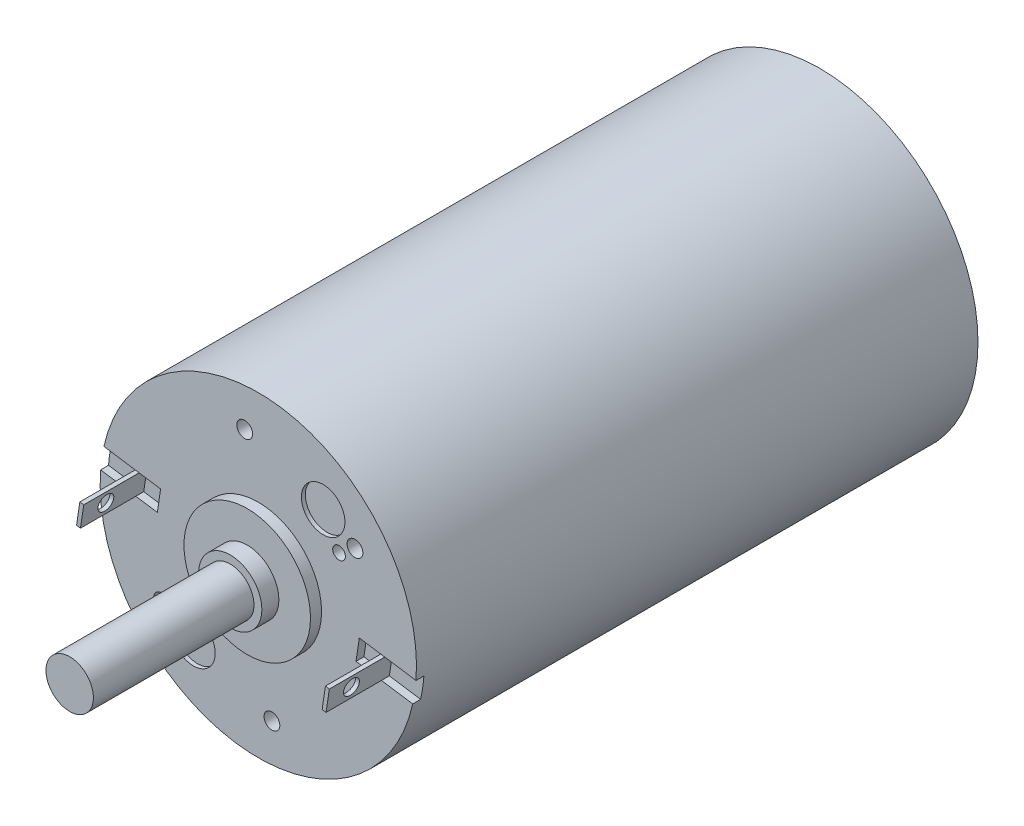
from build123d import *

# Parameters (mm, degrees)
SKETCH1_R           = 20
BOSS_EXTRUDE1_DEPTH = 71
SKETCH2_R           = 8
BOSS_EXTRUDE2_DEPTH = 1.4
SKETCH3_R           = 4
BOSS_EXTRUDE3_DEPTH = 2.15
SKETCH4_R           = 3
BOSS_EXTRUDE4_DEPTH = 20.3
SKETCH5_R           = 1
SKETCH5_R_2         = 0.8
CUT_EXTRUDE1_DEPTH  = 3
CUT_EXTRUDE2_DEPTH  = 1
BOSS_EXTRUDE5_DEPTH = 8
SKETCH8_R           = 2.75
CUT_EXTRUDE3_DEPTH  = 0.5
CUT_EXTRUDE4_REACH  = 105.809
SKETCH9_R           = 1
CUT_EXTRUDE5_REACH  = 137.209
CUT_EXTRUDE5_START  = -31.4
SKETCH9_2_R         = 1
SKETCH10_R          = 1.5
SKETCH10_R_2        = 1.75
CUT_EXTRUDE6_DEPTH  = 5


with BuildPart() as part:
    # Sketch1 → Boss-Extrude1 (new body)
    with BuildSketch(Plane.XY):
        Circle(SKETCH1_R)
    extrude(amount=BOSS_EXTRUDE1_DEPTH)

    # Sketch2 → Boss-Extrude2 (add)
    with BuildSketch(Plane.XY.offset(71)):
        Circle(SKETCH2_R)
    extrude(amount=BOSS_EXTRUDE2_DEPTH)

    # Sketch3 → Boss-Extrude3 (add)
    with BuildSketch(Plane.XY.offset(72.4)):
        Circle(SKETCH3_R)
    extrude(amount=BOSS_EXTRUDE3_DEPTH)

    # Sketch4 → Boss-Extrude4 (add)
    with BuildSketch(Plane.XY.offset(74.55)):
        Circle(SKETCH4_R)
    extrude(amount=BOSS_EXTRUDE4_DEPTH)

    # Sketch5 → Cut-Extrude1 (cut)
    with BuildSketch(Plane.XY.offset(71)):
        with Locations((12.218624281, 9.041306359)):
            Circle(SKETCH5_R)
        with Locations((-12.218624281, -9.041306359)):
            Circle(SKETCH5_R)
        with Locations((-1.720688849, 15.102292206)):
            Circle(SKETCH5_R)
        with Locations((1.720688849, -15.102292206)):
            Circle(SKETCH5_R)
        with Locations((10.20898213, 7.554249392)):
            Circle(SKETCH5_R_2)
        with Locations((-10.20898213, -7.554249392)):
            Circle(SKETCH5_R_2)
    extrude(amount=-CUT_EXTRUDE1_DEPTH, mode=Mode.SUBTRACT)

    # Sketch6 → Cut-Extrude2 (cut)
    with BuildSketch(Plane.XY.offset(71)):
        Polygon((-19.987250443, 1.571566014), (-12.76743464, 0.492557313), (-12.353568289, 3.26180173), (-19.573384092, 4.340810431), align=None)
        Polygon((19.573384092, -4.340810431), (12.353568289, -3.26180173), (12.76743464, -0.492557313), (19.987250443, -1.571566014), align=None)
    extrude(amount=-CUT_EXTRUDE2_DEPTH, mode=Mode.SUBTRACT)

    # Sketch7 → Boss-Extrude5 (add)
    with BuildSketch(Plane.XY.offset(70)):
        Polygon((-15.981736196, 0.972937899), (-15.567869845, 3.742182316), (-15.073361913, 3.668277611), (-15.487228265, 0.899033193), align=None)
        Polygon((15.567869845, -3.742182316), (15.981736196, -0.972937899), (15.487228265, -0.899033193), (15.073361913, -3.668277611), align=None)
    extrude(amount=BOSS_EXTRUDE5_DEPTH)

    # Sketch8 → Cut-Extrude3 (cut)
    with BuildSketch(Plane.XY.offset(71)):
        with Locations((8.199604269, 11.285787072)):
            Circle(SKETCH8_R)
        with Locations((-8.199604269, -11.285787072)):
            Circle(SKETCH8_R)
    extrude(amount=-CUT_EXTRUDE3_DEPTH, mode=Mode.SUBTRACT)

    # Sketch9 → Cut-Extrude4 (cut, up to next)
    with BuildSketch(Plane(origin=(15.774803021, -2.357560108, 0), x_dir=(0, 0, -1), z_dir=(0.9890158633619179, -0.147809411129604, 0)), mode=Mode.PRIVATE) as cut_extrude4_sk1:
        with Locations((-75, 0)):
            Circle(SKETCH9_R)
    cut_extrude4_tool1 = extrude(cut_extrude4_sk1.sketch, amount=-CUT_EXTRUDE4_REACH, mode=Mode.PRIVATE) & part.part
    add(cut_extrude4_tool1.solids().sort_by_distance((15.774803, -2.35756, 75))[0], mode=Mode.SUBTRACT)

    # Sketch9_2 → Cut-Extrude5 (cut, up to next)
    with BuildSketch(Plane(origin=(15.774803021, -2.357560108, 0), x_dir=(0, 0, -1), z_dir=(0.9890158633619179, -0.147809411129604, 0)).offset(CUT_EXTRUDE5_START), mode=Mode.PRIVATE) as cut_extrude5_sk1:
        with Locations((-75, 0)):
            Circle(SKETCH9_2_R)
    cut_extrude5_tool1 = extrude(cut_extrude5_sk1.sketch, amount=-CUT_EXTRUDE5_REACH, mode=Mode.PRIVATE) & part.part
    add(cut_extrude5_tool1.solids().sort_by_distance((-15.280295, 2.283655, 75))[0], mode=Mode.SUBTRACT)

    # Sketch10 → Cut-Extrude6 (cut)
    with BuildSketch(Plane(origin=(0, 0, 0), x_dir=(-1, 0, 0), z_dir=(0, 0, -1))):
        with Locations((0, 11)):
            Circle(SKETCH10_R)
        with Locations((9.526279442, 5.5)):
            Circle(SKETCH10_R)
        with Locations((9.526279442, -5.5)):
            Circle(SKETCH10_R)
        with Locations((0, -11)):
            Circle(SKETCH10_R)
        with Locations((-9.526279442, -5.5)):
            Circle(SKETCH10_R)
        with Locations((-9.526279442, 5.5)):
            Circle(SKETCH10_R)
        with Locations((0, 16)):
            Circle(SKETCH10_R_2)
    extrude(amount=-CUT_EXTRUDE6_DEPTH, mode=Mode.SUBTRACT)


solid = part.part
